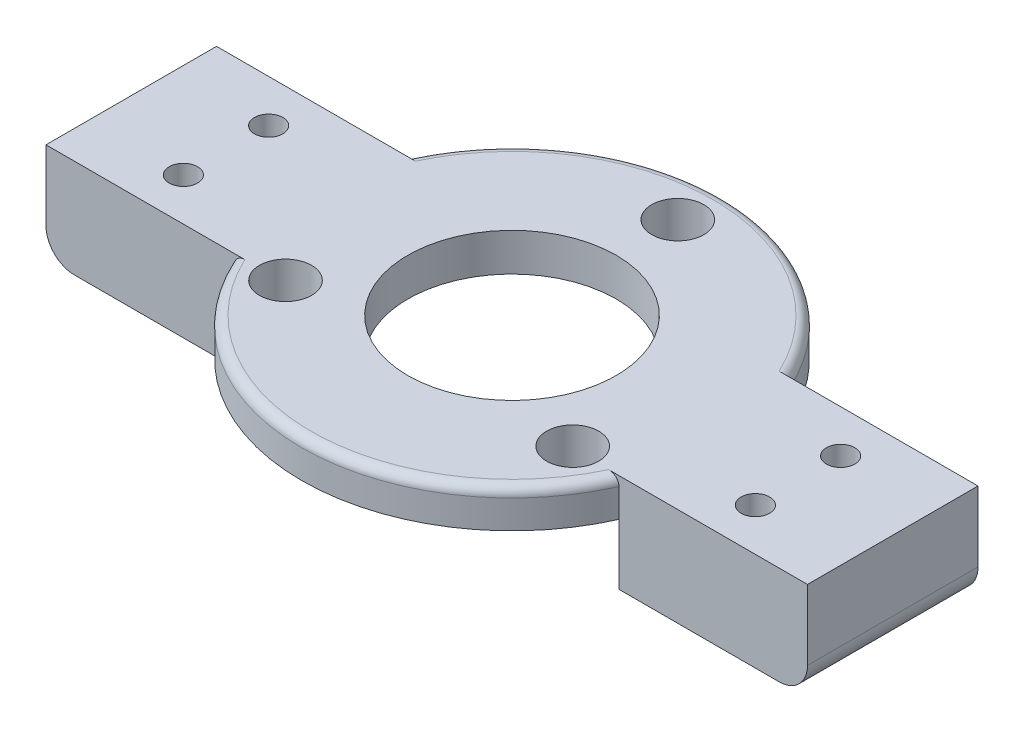
from build123d import *

# Parameters (mm, degrees)
SKETCH1_R                = 17.45
SKETCH1_R_2              = 12.45
BOSS_EXTRUDE1_DEPTH      = 8
SKETCH2_R                = 20
SKETCH2_R_2              = 12.45
BOSS_EXTRUDE2_DEPTH      = 2
SKETCH3_R                = 32.5
SKETCH3_R_2              = 12.45
BOSS_EXTRUDE3_DEPTH      = 4
FILLET1_R                = 1
BOSS_EXTRUDE6_START      = -4
SKETCH10_W               = 10
SKETCH10_H               = 18
BOSS_EXTRUDE6_DEPTH      = 4
SKETCH4_W                = 6
SKETCH4_H                = 18
BOSS_EXTRUDE4_DEPTH      = 75
BOSS_EXTRUDE4_DEPTH_BACK = 4
SKETCH5_R                = 5.05
CUT_EXTRUDE1_DEPTH       = 306
CUT_EXTRUDE1_DEPTH_BACK  = 113
SKETCH6_W                = 6
SKETCH6_H                = 10
BOSS_EXTRUDE5_DEPTH      = 15
BOSS_EXTRUDE5_DEPTH_BACK = 32.85
SKETCH7_R                = 1.629220746
SKETCH7_R_2              = 1.580258945
CUT_EXTRUDE2_DEPTH       = 10
SKETCH9_R                = 5.05
CUT_EXTRUDE3_DEPTH       = 10
CUT_EXTRUDE3_DEPTH_BACK  = 10
SKETCH11_W               = 9.782596874
SKETCH11_H               = 3.234517514
CUT_EXTRUDE4_DEPTH       = 123
CUT_EXTRUDE4_DEPTH_BACK  = 61
FILLET4_R                = 3
FILLET5_R                = 3
SKETCH12_W               = 108.791398151
SKETCH12_H               = 24.041848298
CUT_EXTRUDE5_DEPTH       = 110.678
SKETCH15_R               = 22
CUT_EXTRUDE7_DEPTH       = 4
SKETCH13_R               = 22
SKETCH13_R_2             = 11
SKETCH13_R_3             = 2.75
BOSS_EXTRUDE7_DEPTH      = 4
FILLET6_R                = 3
CUT_EXTRUDE8_DEPTH       = 5
FILLET7_R                = 1
BOSS_EXTRUDE8_START      = -3
BOSS_EXTRUDE8_DEPTH      = 9.4
FILLET8_R                = 3
FILLET8_OF_MIRROR2_R     = 3
CUT_EXTRUDE12_START      = -6
SKETCH21_R               = 6.05
CUT_EXTRUDE12_DEPTH      = 3.8
SKETCH18_W               = 88.746975794
SKETCH18_H               = 20.386854219
CUT_EXTRUDE9_DEPTH       = 10
SKETCH19_W               = 6
SKETCH19_H               = 10.45
BOSS_EXTRUDE9_DEPTH      = 5
FILLET9_R                = 2
CUT_EXTRUDE13_DEPTH      = 2
SKETCH23_R               = 1
CUT_EXTRUDE14_DEPTH      = 11
CUT_EXTRUDE16_DEPTH      = 1.7
SKETCH26_W               = 136.459260558
SKETCH26_H               = 86.542262852
CUT_EXTRUDE17_DEPTH      = 100
CUT_EXTRUDE17_DEPTH_BACK = 100
SKETCH27_R               = 1.5
CUT_EXTRUDE18_DEPTH      = 100
CUT_EXTRUDE19_DEPTH      = 5


with BuildPart() as part:
    # Sketch1 → Boss-Extrude1 (new body)
    with BuildSketch(Plane(origin=(0, 0, 0), x_dir=(1, 0, 0), z_dir=(0, 1, 0))):
        Circle(SKETCH1_R)
        Circle(SKETCH1_R_2, mode=Mode.SUBTRACT)
    extrude(amount=BOSS_EXTRUDE1_DEPTH)

    # Sketch2 → Boss-Extrude2 (add)
    with BuildSketch(Plane(origin=(0, 8, 0), x_dir=(1, 0, 0), z_dir=(0, 1, 0))):
        Circle(SKETCH2_R)
        Circle(SKETCH2_R_2, mode=Mode.SUBTRACT)
    extrude(amount=BOSS_EXTRUDE2_DEPTH)

    # Sketch3 → Boss-Extrude3 (add)
    with BuildSketch(Plane(origin=(0, 10, 0), x_dir=(1, 0, 0), z_dir=(0, 1, 0))):
        Circle(SKETCH3_R)
        Circle(SKETCH3_R_2, mode=Mode.SUBTRACT)
    extrude(amount=BOSS_EXTRUDE3_DEPTH)

    # Fillet1
    fillet1_edges = [part.edges().sort_by_distance(p)[0] for p in [
        (-32.5, 14, 0),
    ]]
    fillet(fillet1_edges, radius=FILLET1_R)

    # Sketch10 → Boss-Extrude6 (add)
    with BuildSketch(Plane(origin=(0, 14, 0), x_dir=(1, 0, 0), z_dir=(0, 1, 0)).offset(BOSS_EXTRUDE6_START)):
        with Locations((35.186917696, 0)):
            Rectangle(SKETCH10_W, SKETCH10_H)
        with Locations((-35.186917696, 0)):
            Rectangle(SKETCH10_W, SKETCH10_H)
    extrude(amount=BOSS_EXTRUDE6_DEPTH)

    # Sketch4 → Boss-Extrude4 (add, two sides)
    with BuildSketch(Plane(origin=(0, 14, 0), x_dir=(1, 0, 0), z_dir=(0, 1, 0))) as boss_extrude4_sk:
        with Locations((-37.186917696, 0)):
            Rectangle(SKETCH4_W, SKETCH4_H)
        with Locations((37.186917696, 0)):
            Rectangle(SKETCH4_W, SKETCH4_H)
    extrude(amount=BOSS_EXTRUDE4_DEPTH)
    extrude(boss_extrude4_sk.sketch, amount=-BOSS_EXTRUDE4_DEPTH_BACK)

    # Sketch5 → Cut-Extrude1 (cut, two sides)
    with BuildSketch(Plane.ZY.offset(-34.186917696)) as cut_extrude1_sk:
        with Locations((0, 79)):
            Circle(SKETCH5_R)
    extrude(amount=CUT_EXTRUDE1_DEPTH, mode=Mode.SUBTRACT)
    extrude(cut_extrude1_sk.sketch, amount=-CUT_EXTRUDE1_DEPTH_BACK, mode=Mode.SUBTRACT)

    # Sketch6 → Boss-Extrude5 (add, two sides)
    with BuildSketch(Plane(origin=(0, 0, -9), x_dir=(-1, 0, 0), z_dir=(0, 0, -1))) as boss_extrude5_sk:
        with Locations((37.186917696, 70.95)):
            Rectangle(SKETCH6_W, SKETCH6_H)
    extrude(amount=BOSS_EXTRUDE5_DEPTH)
    extrude(boss_extrude5_sk.sketch, amount=-BOSS_EXTRUDE5_DEPTH_BACK)

    # Sketch7 → Cut-Extrude2 (cut)
    with BuildSketch(Plane(origin=(-34.186917696, 0, 0), x_dir=(0, 0, -1), z_dir=(1, 0, 0))):
        with Locations((-17.5, 71)):
            Circle(SKETCH7_R)
        with Locations((17.5, 71)):
            Circle(SKETCH7_R_2)
    extrude(amount=-CUT_EXTRUDE2_DEPTH, mode=Mode.SUBTRACT)

    # Sketch9 → Cut-Extrude3 (cut, two sides)
    with BuildSketch(Plane(origin=(-34.186917696, 0, 0), x_dir=(0, 0, -1), z_dir=(1, 0, 0))) as cut_extrude3_sk:
        with Locations((0, 79)):
            Circle(SKETCH9_R)
    extrude(amount=CUT_EXTRUDE3_DEPTH, mode=Mode.SUBTRACT)
    extrude(cut_extrude3_sk.sketch, amount=-CUT_EXTRUDE3_DEPTH_BACK, mode=Mode.SUBTRACT)

    # Sketch11 → Cut-Extrude4 (cut, two sides)
    with BuildSketch(Plane.ZY.offset(-34.186917696)) as cut_extrude4_sk:
        with Locations((0, 15.617258757)):
            Rectangle(SKETCH11_W, SKETCH11_H)
    extrude(amount=CUT_EXTRUDE4_DEPTH, mode=Mode.SUBTRACT)
    extrude(cut_extrude4_sk.sketch, amount=-CUT_EXTRUDE4_DEPTH_BACK, mode=Mode.SUBTRACT)

    # Fillet4
    fillet4_edges = [part.edges().sort_by_distance(p)[0] for p in [
        (-37.186917696, 65.95, 23.85),
        (-37.186917696, 75.95, 23.85),
        (-37.186917696, 65.95, -24),
        (-37.186917696, 75.95, -24),
        (-37.186917696, 89, -9),
        (-37.186917696, 89, 9),
    ]]
    fillet(fillet4_edges, radius=FILLET4_R)

    # Fillet5
    fillet5_edges = [part.edges().sort_by_distance(p)[0] for p in [
        (40.186917696, 10, 0),
        (-40.186917696, 10, 0),
    ]]
    fillet(fillet5_edges, radius=FILLET5_R)

    # Sketch12 → Cut-Extrude5 (cut)
    with BuildSketch(Plane(origin=(40.186917696, 0, 0), x_dir=(0, 0, -1), z_dir=(1, 0, 0))):
        with Locations((-12.502918017, -2.020924149)):
            Rectangle(SKETCH12_W, SKETCH12_H)
    extrude(amount=-CUT_EXTRUDE5_DEPTH, mode=Mode.SUBTRACT)

    # Sketch15 → Cut-Extrude7 (cut)
    with BuildSketch(Plane(origin=(0, 14, 0), x_dir=(1, 0, 0), z_dir=(0, 1, 0))):
        Circle(SKETCH15_R)
    extrude(amount=-CUT_EXTRUDE7_DEPTH, mode=Mode.SUBTRACT)

    # Sketch13 → Boss-Extrude7 (add)
    with BuildSketch(Plane(origin=(0, 14, 0), x_dir=(1, 0, 0), z_dir=(0, 1, 0))):
        Circle(SKETCH13_R)
        Circle(SKETCH13_R_2, mode=Mode.SUBTRACT)
        with Locations((0, 17.5)):
            Circle(SKETCH13_R_3, mode=Mode.SUBTRACT)
        with Locations((-15.155444566, -8.75)):
            Circle(SKETCH13_R_3, mode=Mode.SUBTRACT)
        with Locations((15.155444566, -8.75)):
            Circle(SKETCH13_R_3, mode=Mode.SUBTRACT)
    extrude(amount=-BOSS_EXTRUDE7_DEPTH)

    # Fillet6
    fillet6_edges = [part.edges().sort_by_distance(p)[0] for p in [
        (37.186917696, 89, 9),
        (37.186917696, 89, -9),
    ]]
    fillet(fillet6_edges, radius=FILLET6_R)

    # Sketch16 → Cut-Extrude8 (cut)
    with BuildSketch(Plane.XZ.offset(-10)):
        with BuildLine():
            Line((-31.228992939, 9), (-20.29384143, 9))
            ThreePointArc((-20.29384143, 9), (0, 22.2), (20.29384143, 9))
            Line((20.29384143, 9), (31.228992939, 9))
            ThreePointArc((31.228992939, 9), (0, 32.5), (-31.228992939, 9))
        make_face()
    cut_extrude8 = extrude(amount=-CUT_EXTRUDE8_DEPTH, mode=Mode.SUBTRACT)

    # Mirror1: Cut-Extrude8 across plane
    add(cut_extrude8.mirror(Plane.XY), mode=Mode.SUBTRACT)

    # Fillet7
    fillet7_edges = [part.edges().sort_by_distance(p)[0] for p in [
        (0, 14, 22.2),
        (0, 14, -22.2),
    ]]
    fillet(fillet7_edges, radius=FILLET7_R)

    # Sketch17 → Boss-Extrude8 (add)
    with BuildSketch(Plane.XZ.offset(-10).offset(BOSS_EXTRUDE8_START)):
        with BuildLine():
            Line((20.29384143, -9), (40.186917696, -9))
            Line((40.186917696, -9), (40.186917696, 9))
            Line((40.186917696, 9), (20.29384143, 9))
            ThreePointArc((20.29384143, 9), (22.2, 0), (20.29384143, -9))
        make_face()
    boss_extrude8 = extrude(amount=BOSS_EXTRUDE8_DEPTH)

    # Fillet8
    fillet8_edges = [part.edges().sort_by_distance(p)[0] for p in [
        (40.186917696, 3.6, 0),
    ]]
    fillet(fillet8_edges, radius=FILLET8_R)

    # Mirror2: Boss-Extrude8 across plane
    add(boss_extrude8.mirror(Plane(origin=(0, 0, 0), x_dir=(0, 0, 1), z_dir=(1, 0, 0))))

    # Fillet8 of Mirror2
    fillet8_of_mirror2_edges = [part.edges().sort_by_distance(p)[0] for p in [
        (-40.186917696, 3.6, 0),
    ]]
    fillet(fillet8_of_mirror2_edges, radius=FILLET8_OF_MIRROR2_R)

    # Sketch21 → Cut-Extrude12 (cut)
    with BuildSketch(Plane(origin=(40.186917696, 0, 0), x_dir=(0, 0, -1), z_dir=(1, 0, 0)).offset(CUT_EXTRUDE12_START)):
        with Locations((0, 79)):
            Circle(SKETCH21_R)
    extrude(amount=CUT_EXTRUDE12_DEPTH, mode=Mode.SUBTRACT)

    # Sketch18 → Cut-Extrude9 (cut)
    with BuildSketch(Plane(origin=(40.186917696, 0, 0), x_dir=(0, 0, -1), z_dir=(1, 0, 0))):
        with Locations((0, 89.193427109)):
            Rectangle(SKETCH18_W, SKETCH18_H)
    extrude(amount=-CUT_EXTRUDE9_DEPTH, mode=Mode.SUBTRACT)

    # Sketch19 → Boss-Extrude9 (add)
    with BuildSketch(Plane(origin=(0, 79, 0), x_dir=(1, 0, 0), z_dir=(0, 1, 0))):
        with Locations((37.186917696, -11.275)):
            Rectangle(SKETCH19_W, SKETCH19_H)
        with Locations((37.186917696, 11.275)):
            Rectangle(SKETCH19_W, SKETCH19_H)
    extrude(amount=-BOSS_EXTRUDE9_DEPTH)

    # Fillet9
    fillet9_edges = [part.edges().sort_by_distance(p)[0] for p in [
        (37.186917696, 74, 16.5),
        (37.186917696, 74, -16.5),
    ]]
    fillet(fillet9_edges, radius=FILLET9_R)

    # Sketch22 → Cut-Extrude13 (cut)
    with BuildSketch(Plane(origin=(-34.186917696, 0, 0), x_dir=(0, 0, -1), z_dir=(1, 0, 0))):
        Polygon((-15.9988893, 68.4), (-14.4977786, 71), (-15.9988893, 73.6), (-19.0011107, 73.6), (-20.5022214, 71), (-19.0011107, 68.4), align=None)
        Polygon((20.5022214, 71), (19.0011107, 73.6), (15.9988893, 73.6), (14.4977786, 71), (15.9988893, 68.4), (19.0011107, 68.4), align=None)
    extrude(amount=-CUT_EXTRUDE13_DEPTH, mode=Mode.SUBTRACT)

    # Sketch23 → Cut-Extrude14 (cut)
    with BuildSketch(Plane(origin=(0, 79, 0), x_dir=(1, 0, 0), z_dir=(0, 1, 0))):
        with Locations((37.186917696, -12.3)):
            Circle(SKETCH23_R)
        with Locations((37.186917696, 12.3)):
            Circle(SKETCH23_R)
    extrude(amount=-CUT_EXTRUDE14_DEPTH, mode=Mode.SUBTRACT)

    # Sketch24 → Cut-Extrude16 (cut)
    with BuildSketch(Plane.XZ.offset(-74)):
        Polygon((37.186917696, 9.990598923), (39.186917696, 11.145299462), (39.186917696, 13.454700538), (37.186917696, 14.609401077), (35.186917696, 13.454700538), (35.186917696, 11.145299462), align=None)
        Polygon((37.186917696, -14.609401077), (39.186917696, -13.454700538), (39.186917696, -11.145299462), (37.186917696, -9.990598923), (35.186917696, -11.145299462), (35.186917696, -13.454700538), align=None)
    extrude(amount=-CUT_EXTRUDE16_DEPTH, mode=Mode.SUBTRACT)

    # Sketch26 → Cut-Extrude17 (cut, two sides)
    with BuildSketch(Plane(origin=(0, 0, -9), x_dir=(-1, 0, 0), z_dir=(0, 0, -1))) as cut_extrude17_sk:
        with Locations((-1.263679096, 57.271131426)):
            Rectangle(SKETCH26_W, SKETCH26_H)
    extrude(amount=CUT_EXTRUDE17_DEPTH, mode=Mode.SUBTRACT)
    extrude(cut_extrude17_sk.sketch, amount=-CUT_EXTRUDE17_DEPTH_BACK, mode=Mode.SUBTRACT)

    # Sketch27 → Cut-Extrude18 (cut)
    with BuildSketch(Plane(origin=(0, 14, 0), x_dir=(1, 0, 0), z_dir=(0, 1, 0))):
        with Locations((30.186917696, -4.5)):
            Circle(SKETCH27_R)
        with Locations((30.186917696, 4.5)):
            Circle(SKETCH27_R)
        with Locations((-30.186917696, -4.5)):
            Circle(SKETCH27_R)
        with Locations((-30.186917696, 4.5)):
            Circle(SKETCH27_R)
    extrude(amount=-CUT_EXTRUDE18_DEPTH, mode=Mode.SUBTRACT)

    # Sketch28 → Cut-Extrude19 (cut)
    with BuildSketch(Plane.XZ.offset(-3.6)):
        Polygon((27.011491216, -4.5), (28.599204456, -7.25), (31.774630937, -7.25), (33.362344177, -4.5), (31.774630937, -1.75), (28.599204456, -1.75), align=None)
        Polygon((27.011491216, 4.5), (28.599204456, 1.75), (31.774630937, 1.75), (33.362344177, 4.5), (31.774630937, 7.25), (28.599204456, 7.25), align=None)
        Polygon((-33.362344177, 4.5), (-31.774630937, 1.75), (-28.599204456, 1.75), (-27.011491216, 4.5), (-28.599204456, 7.25), (-31.774630937, 7.25), align=None)
        Polygon((-33.362344177, -4.5), (-31.774630937, -7.25), (-28.599204456, -7.25), (-27.011491216, -4.5), (-28.599204456, -1.75), (-31.774630937, -1.75), align=None)
    extrude(amount=-CUT_EXTRUDE19_DEPTH, mode=Mode.SUBTRACT)


solid = part.part
